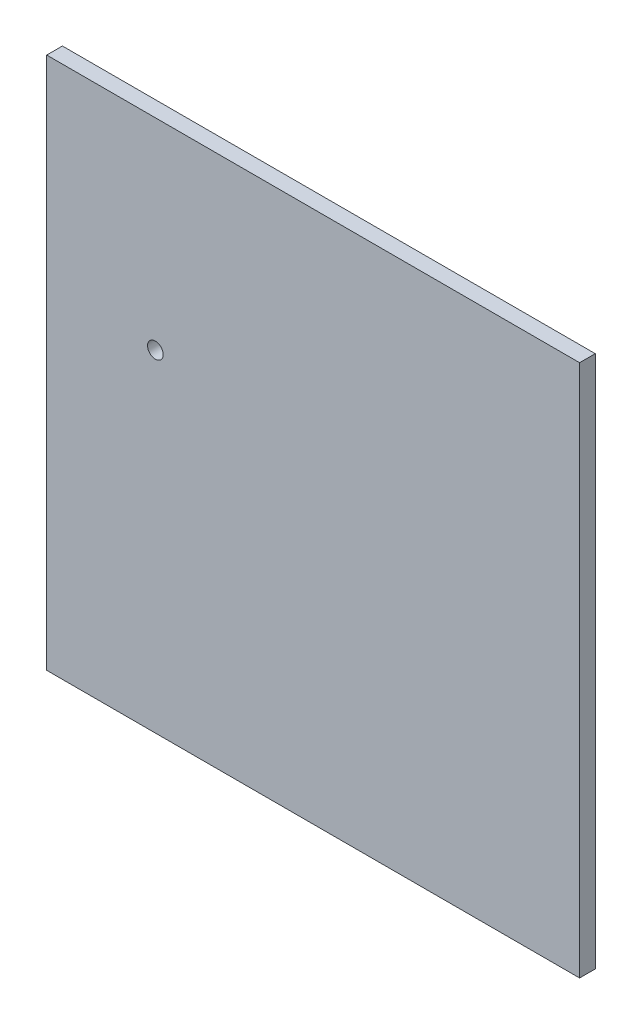
from build123d import *

# Parameters (mm, degrees)
ESQUISSE3_W             = 34
ESQUISSE3_H             = 34
BOSS_EXTRU_1_DEPTH      = 1
SKETCH_HOLES_R          = 0.5
CUT_EXTRUDE_HOLES_DEPTH = 2


with BuildPart() as part:
    # Esquisse3 → Boss.-Extru.1 (new body)
    with BuildSketch(Plane(origin=(0, 0, 0), x_dir=(0, 1, 0), z_dir=(0, 0, 1))):
        Rectangle(ESQUISSE3_W, ESQUISSE3_H)
    extrude(amount=BOSS_EXTRU_1_DEPTH)

    # Sketch_Holes → Cut_Extrude_Holes (cut, through all)
    with BuildSketch(Plane.XY.offset(1)):
        with Locations((-10.067654011, 4.160184375)):
            Circle(SKETCH_HOLES_R)
    extrude(amount=-CUT_EXTRUDE_HOLES_DEPTH, mode=Mode.SUBTRACT)


solid = part.part
